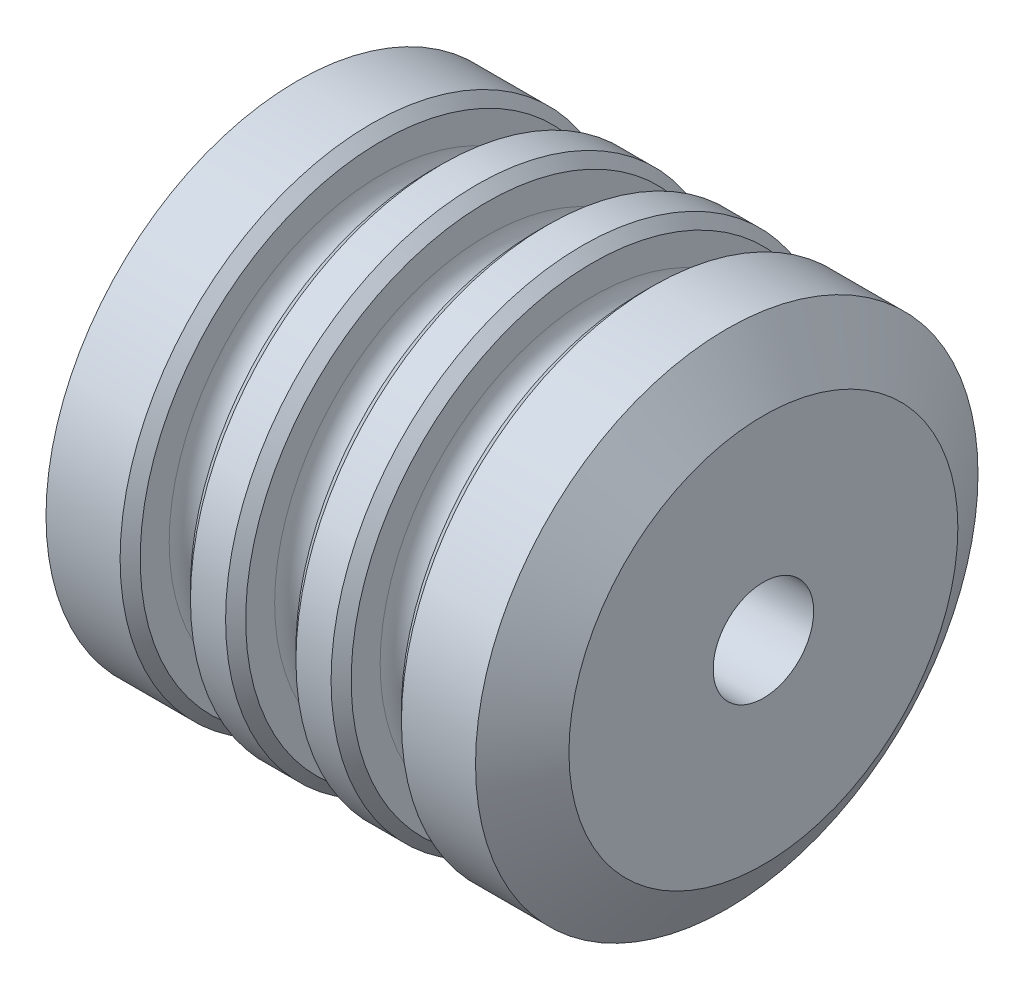
from build123d import *

# Parameters (mm, degrees)
SKETCH3_R          = 50
CUT_EXTRUDE1_DEPTH = 550


with BuildPart() as part:
    # Sketch2 → Revolve1 (revolve)
    with BuildSketch(Plane.XY):
        with BuildLine():
            Line((0, 0), (0, 193.507761945))
            Line((0, 193.507761945), (-36.461372265, 250))
            Line((-36.461372265, 250), (-110.195831317, 250))
            Line((-110.195831317, 250), (-120.195831317, 240))
            Line((-120.195831317, 240), (-120.195831317, 211.162162162))
            ThreePointArc((-120.195831317, 211.162162162), (-127.225268569, 194.191599414), (-144.195831317, 187.162162162))
            Line((-144.195831317, 187.162162162), (-146.195831317, 187.162162162))
            ThreePointArc((-146.195831317, 187.162162162), (-163.166394066, 194.191599414), (-170.195831317, 211.162162162))
            Line((-170.195831317, 211.162162162), (-170.195831317, 240))
            Line((-170.195831317, 240), (-180.195831317, 250))
            Line((-180.195831317, 250), (-215.163253655, 250))
            Line((-215.163253655, 250), (-225.163253655, 240))
            Line((-225.163253655, 240), (-225.163253655, 211.162162162))
            ThreePointArc((-225.163253655, 211.162162162), (-232.192690907, 194.191599414), (-249.163253655, 187.162162162))
            Line((-249.163253655, 187.162162162), (-251.163253655, 187.162162162))
            ThreePointArc((-251.163253655, 187.162162162), (-268.133816404, 194.191599414), (-275.163253655, 211.162162162))
            Line((-275.163253655, 211.162162162), (-275.163253655, 240))
            Line((-275.163253655, 240), (-285.163253655, 250))
            Line((-285.163253655, 250), (-320.130675994, 250))
            Line((-320.130675994, 250), (-330.130675994, 240))
            Line((-330.130675994, 240), (-330.130675994, 211.162162162))
            ThreePointArc((-330.130675994, 211.162162162), (-337.160113245, 194.191599414), (-354.130675994, 187.162162162))
            Line((-354.130675994, 187.162162162), (-356.130675994, 187.162162162))
            ThreePointArc((-356.130675994, 187.162162162), (-373.101238742, 194.191599414), (-380.130675994, 211.162162162))
            Line((-380.130675994, 211.162162162), (-380.130675994, 240))
            Line((-380.130675994, 240), (-390.130675994, 250))
            Line((-390.130675994, 250), (-463.865135046, 250))
            Line((-463.865135046, 250), (-500.326507311, 193.507761945))
            Line((-500.326507311, 193.507761945), (-500.326507311, 0))
            Line((-500.326507311, 0), (0, 0))
        make_face()
    revolve(axis=Axis((0, 0, 0), (-1, 0, 0)))

    # Sketch3 → Cut-Extrude1 (cut)
    with BuildSketch(Plane(origin=(0, 0, 0), x_dir=(0, 0, -1), z_dir=(1, 0, 0))):
        Circle(SKETCH3_R)
    extrude(amount=-CUT_EXTRUDE1_DEPTH, mode=Mode.SUBTRACT)


solid = part.part
